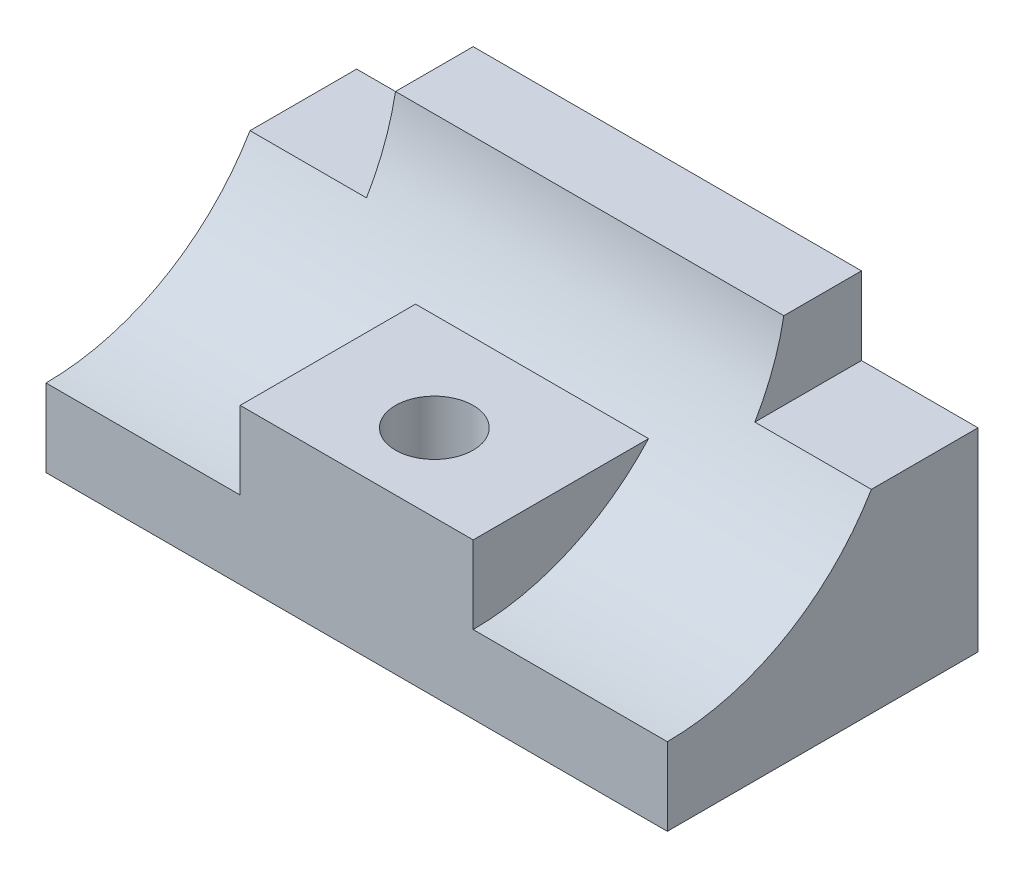
from build123d import *

# Parameters (mm, degrees)
SALIENTE_EXTRUIR1_DEPTH    = 80
CROQUIS2_W                 = 30
CROQUIS2_H                 = 20
CORTAR_EXTRUIR1_DEPTH      = 81
CORTAR_EXTRUIR1_DEPTH_BACK = 1
CROQUIS3_W                 = 60
CROQUIS3_H                 = 40
SALIENTE_EXTRUIR2_DEPTH    = 80
CROQUIS4_R                 = 10
CORTAR_EXTRUIR2_DEPTH      = 40


with BuildPart() as part:
    # Croquis1 → Saliente-Extruir1 (new body, symmetric)
    with BuildSketch(Plane(origin=(0, 0, 0), x_dir=(0, 0, -1), z_dir=(1, 0, 0))):
        with BuildLine():
            Line((0, 0), (0, 70))
            Line((0, 70), (-20, 70))
            ThreePointArc((-20, 70), (-40.94875162, 34.138501945), (-80, 20))
            Line((-80, 20), (-80, 0))
            Line((-80, 0), (0, 0))
        make_face()
    extrude(amount=SALIENTE_EXTRUIR1_DEPTH, both=True)

    # Croquis2 → Cortar-Extruir1 (cut, two sides)
    with BuildSketch(Plane.XY) as cortar_extruir1_sk:
        with Locations((-65, 60)):
            Rectangle(CROQUIS2_W, CROQUIS2_H)
        with Locations((65, 60)):
            Rectangle(CROQUIS2_W, CROQUIS2_H)
    extrude(amount=CORTAR_EXTRUIR1_DEPTH, mode=Mode.SUBTRACT)
    extrude(cortar_extruir1_sk.sketch, amount=-CORTAR_EXTRUIR1_DEPTH_BACK, mode=Mode.SUBTRACT)

    # Croquis3 → Saliente-Extruir2 (add)
    with BuildSketch(Plane.XY):
        with Locations((0, 20)):
            Rectangle(CROQUIS3_W, CROQUIS3_H)
    extrude(amount=SALIENTE_EXTRUIR2_DEPTH)

    # Croquis4 → Cortar-Extruir2 (cut)
    with BuildSketch(Plane(origin=(0, 0, 0), x_dir=(1, 0, 0), z_dir=(0, 1, 0))):
        with Locations(Location((0, -60, 0), (0, 0, 270))):  # turned: the seam where the file's is
            Circle(CROQUIS4_R)
    extrude(amount=CORTAR_EXTRUIR2_DEPTH, mode=Mode.SUBTRACT)


solid = part.part
